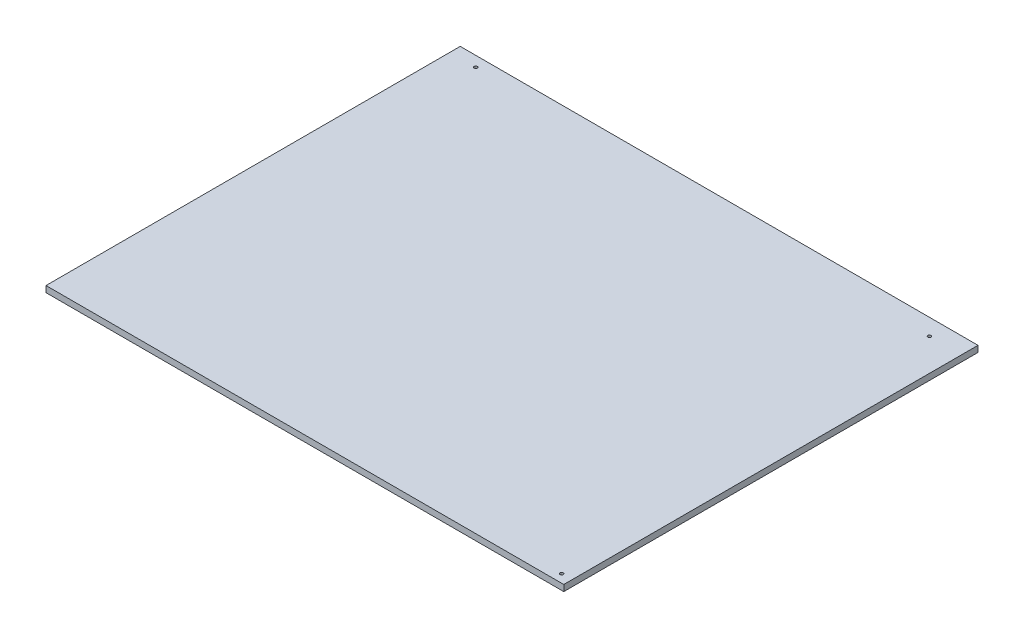
from build123d import *

# Parameters (mm, degrees)
SKETCH1_W           = 500
SKETCH1_H           = 400
SKETCH1_R           = 1.525
SKETCH1_R_2         = 1.5
BOSS_EXTRUDE1_DEPTH = 6


with BuildPart() as part:
    # Sketch1 → Boss-Extrude1 (new body)
    with BuildSketch(Plane(origin=(0, 0, 0), x_dir=(1, 0, 0), z_dir=(0, 1, 0))):
        with Locations((250, -200)):
            Rectangle(SKETCH1_W, SKETCH1_H)
        with Locations((25, -10)):
            Circle(SKETCH1_R, mode=Mode.SUBTRACT)
        with Locations((490, -392)):
            Circle(SKETCH1_R_2, mode=Mode.SUBTRACT)
        with Locations((469, -16)):
            Circle(SKETCH1_R_2, mode=Mode.SUBTRACT)
    extrude(amount=BOSS_EXTRUDE1_DEPTH)


solid = part.part
